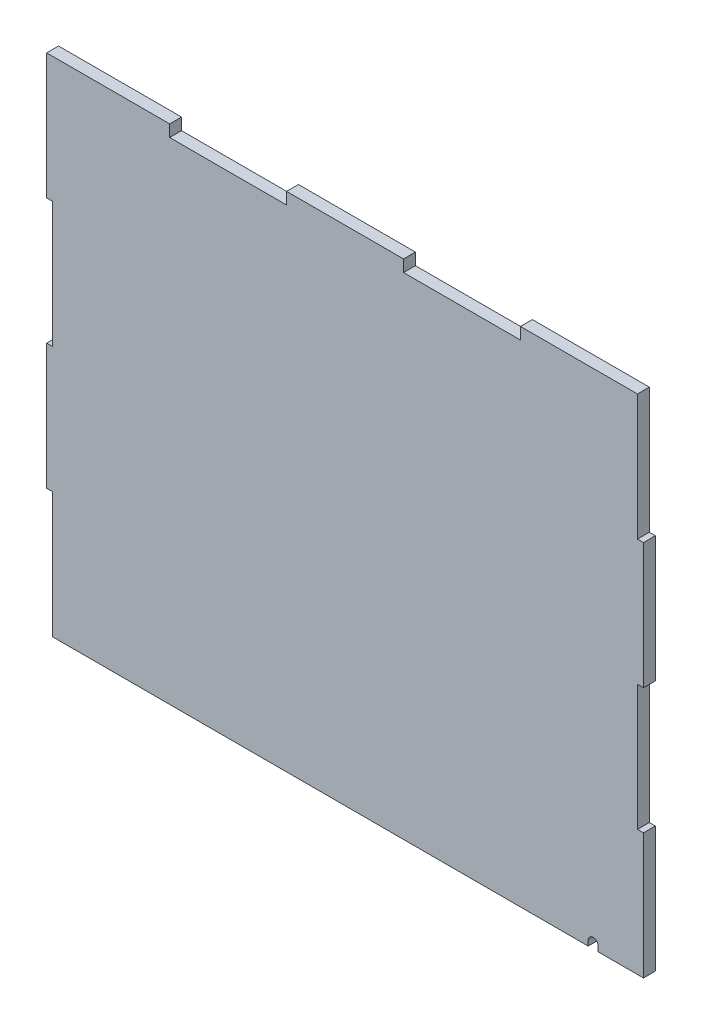
from build123d import *

# Parameters (mm, degrees)
BOSS_EXTRUDE1_DEPTH = 5.9944
CUT_EXTRUDE2_REACH  = 7.994


with BuildPart() as part:
    # Sketch1 → Boss-Extrude1 (new body)
    with BuildSketch(Plane.XY):
        Polygon((-3.048, 63.5), (-3.048, 127), (0, 127), (0, 190.5), (-3.048, 190.5), (-3.048, 253.981711342), (59.0804, 253.981711342), (59.0804, 248.012711342), (118.1608, 248.012711342), (118.1608, 253.981711342), (177.2412, 253.981711342), (177.2412, 248.012711342), (236.3216, 248.012711342), (236.3216, 253.981711342), (295.402, 253.981711342), (295.402, 190.481711342), (298.45, 190.481711342), (298.45, 126.981711342), (295.402, 126.981711342), (295.402, 63.5), (298.45, 63.5), (298.45, 0), (0, 0), (0, 63.5), align=None)
    extrude(amount=BOSS_EXTRUDE1_DEPTH)

    # Sketch2 → Cut-Extrude2 (cut, up to next)
    with BuildSketch(Plane.XY.offset(5.9944), mode=Mode.PRIVATE) as cut_extrude2_sk1:
        with BuildLine():
            Line((270.51, 2.54), (270.51, 0))
            Line((270.51, 0), (275.59, 0))
            Line((275.59, 0), (275.59, 2.54))
            ThreePointArc((275.59, 2.54), (273.05, 5.08), (270.51, 2.54))
        make_face()
    cut_extrude2_tool1 = extrude(cut_extrude2_sk1.sketch, amount=-CUT_EXTRUDE2_REACH, mode=Mode.PRIVATE) & part.part
    add(cut_extrude2_tool1.solids().sort_by_distance((273.05, 2.302891, 5.9944))[0], mode=Mode.SUBTRACT)


solid = part.part
